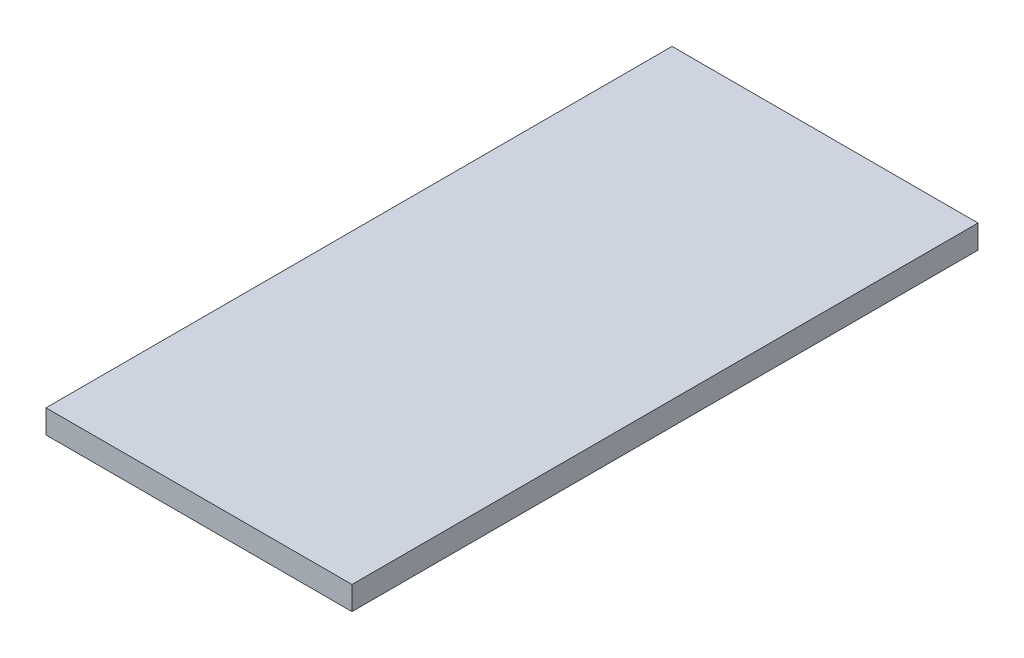
from build123d import *

# Parameters (mm, degrees)
SKETCH1_W           = 130
SKETCH1_H           = 266
BOSS_EXTRUDE1_DEPTH = 10


with BuildPart() as part:
    # Sketch1 → Boss-Extrude1 (new body)
    with BuildSketch(Plane(origin=(0, 0, 0), x_dir=(1, 0, 0), z_dir=(0, 1, 0))):
        with Locations((65, 133)):
            Rectangle(SKETCH1_W, SKETCH1_H)
    extrude(amount=BOSS_EXTRUDE1_DEPTH)


solid = part.part
